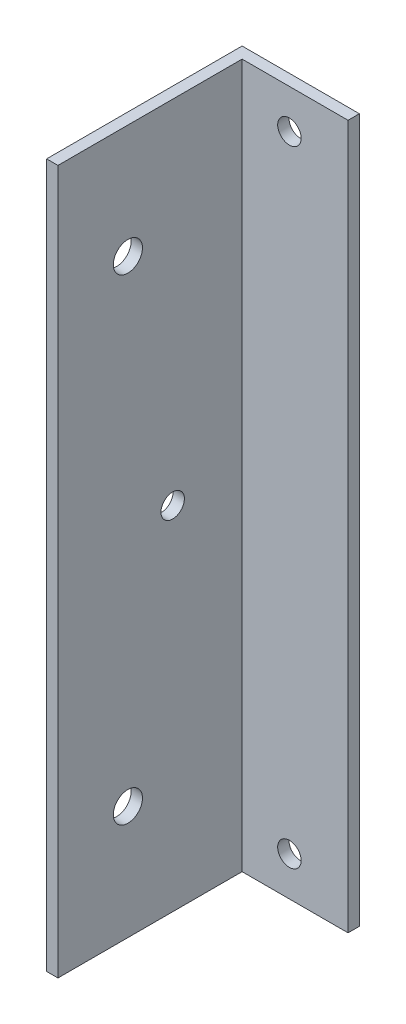
from build123d import *

# Parameters (mm, degrees)
SKETCH1_W           = 15
SKETCH1_H           = 90
BOSS_EXTRUDE1_DEPTH = 1.45
SKETCH2_W           = 1.45
SKETCH2_H           = 90
BOSS_EXTRUDE2_DEPTH = 23.55
SKETCH3_R           = 1.5
CUT_EXTRUDE1_DEPTH  = 26
SKETCH5_R           = 1.865
CUT_EXTRUDE2_DEPTH  = 1.45
CUT_EXTRUDE3_REACH  = 17
SKETCH6_R           = 1.5


with BuildPart() as part:
    # Sketch1 → Boss-Extrude1 (new body)
    with BuildSketch(Plane.XY):
        Rectangle(SKETCH1_W, SKETCH1_H)
    extrude(amount=BOSS_EXTRUDE1_DEPTH)

    # Sketch2 → Boss-Extrude2 (add)
    with BuildSketch(Plane.XY.offset(1.45)):
        with Locations((-6.775, 0)):
            Rectangle(SKETCH2_W, SKETCH2_H)
    extrude(amount=BOSS_EXTRUDE2_DEPTH)

    # Sketch3 → Cut-Extrude1 (cut, through all)
    with BuildSketch(Plane(origin=(0, 0, 0), x_dir=(-1, 0, 0), z_dir=(0, 0, -1))):
        with Locations((0, 40)):
            Circle(SKETCH3_R)
        with Locations((0, -40)):
            Circle(SKETCH3_R)
    extrude(amount=-CUT_EXTRUDE1_DEPTH, mode=Mode.SUBTRACT)

    # Sketch5 → Cut-Extrude2 (cut)
    with BuildSketch(Plane.ZY.offset(7.5)):
        with Locations((16.057, -30.462)):
            Circle(SKETCH5_R)
    cut_extrude2 = extrude(amount=-CUT_EXTRUDE2_DEPTH, mode=Mode.SUBTRACT)

    # Mirror1: Cut-Extrude2 across plane
    add(cut_extrude2.mirror(Plane.ZX), mode=Mode.SUBTRACT)

    # Sketch6 → Cut-Extrude3 (cut, up to next)
    with BuildSketch(Plane.ZY.offset(7.5), mode=Mode.PRIVATE) as cut_extrude3_sk1:
        with Locations((10.33, 0)):
            Circle(SKETCH6_R)
    cut_extrude3_tool1 = extrude(cut_extrude3_sk1.sketch, amount=-CUT_EXTRUDE3_REACH, mode=Mode.PRIVATE) & part.part
    add(cut_extrude3_tool1.solids().sort_by_distance((-7.5, 0, 10.33))[0], mode=Mode.SUBTRACT)


solid = part.part
